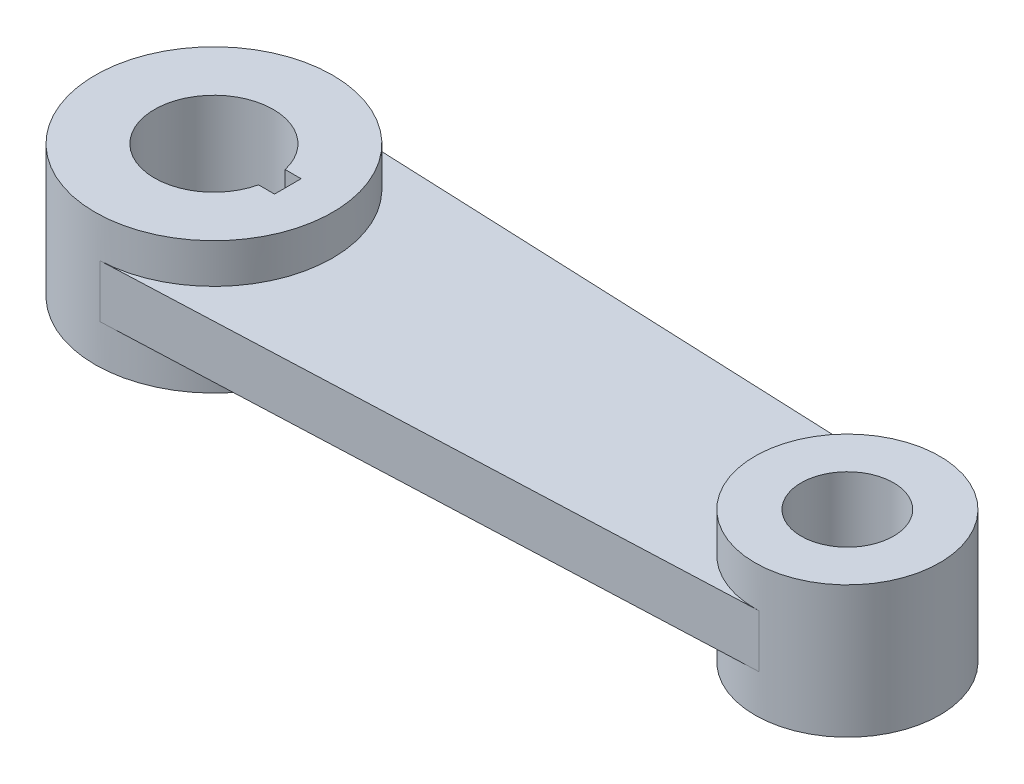
from build123d import *

# Parameters (mm, degrees)
SKETCH1_R             = 56.25
BOSS_EXTRUDE1_DEPTH   = 31.25
SKETCH1_R_2           = 43.75
SKETCH1_R_3           = 21.9
BOSS_EXTRUDE1_2_DEPTH = 31.25
BOSS_EXTRUDE2_START   = 12.5
BOSS_EXTRUDE2_DEPTH   = 25


with BuildPart() as part:
    # Sketch1 → Boss-Extrude1 (new body, symmetric)
    with BuildSketch(Plane(origin=(0, 0, 0), x_dir=(1, 0, 0), z_dir=(0, 1, 0))):
        Circle(SKETCH1_R)
        with BuildLine():
            Line((35, 6.3), (35, -6.3))
            Line((35, -6.3), (27.435970914, -6.3))
            ThreePointArc((27.435970914, -6.3), (-28.15, 0), (27.435970914, 6.3))
            Line((27.435970914, 6.3), (35, 6.3))
        make_face(mode=Mode.SUBTRACT)
    extrude(amount=BOSS_EXTRUDE1_DEPTH, both=True)



with BuildPart() as body_2:
    # Sketch1 → Boss-Extrude1 2 (new body, symmetric)
    with BuildSketch(Plane(origin=(0, 0, 0), x_dir=(1, 0, 0), z_dir=(0, 1, 0))):
        with Locations((300, 0)):
            Circle(SKETCH1_R_2)
        with Locations((300, 0)):
            Circle(SKETCH1_R_3, mode=Mode.SUBTRACT)
    extrude(amount=BOSS_EXTRUDE1_2_DEPTH, both=True)


with BuildPart() as part_1:
    add(part.part)

    add(body_2.part)  # Boss-Extrude2 merges body 2
    # Sketch2 → Boss-Extrude2 (add)
    with BuildSketch(Plane(origin=(0, 0, 0), x_dir=(1, 0, 0), z_dir=(0, 1, 0)).offset(BOSS_EXTRUDE2_START)):
        with BuildLine():
            Line((2.34375, 56.201150664), (301.822916667, 43.712006072))
            ThreePointArc((301.822916667, 43.712006072), (256.25, 0), (301.822916667, -43.712006072))
            Line((301.822916667, -43.712006072), (2.34375, -56.201150664))
            ThreePointArc((2.34375, -56.201150664), (56.25, 0), (2.34375, 56.201150664))
        make_face()
    extrude(amount=-BOSS_EXTRUDE2_DEPTH)


solid = part_1.part
